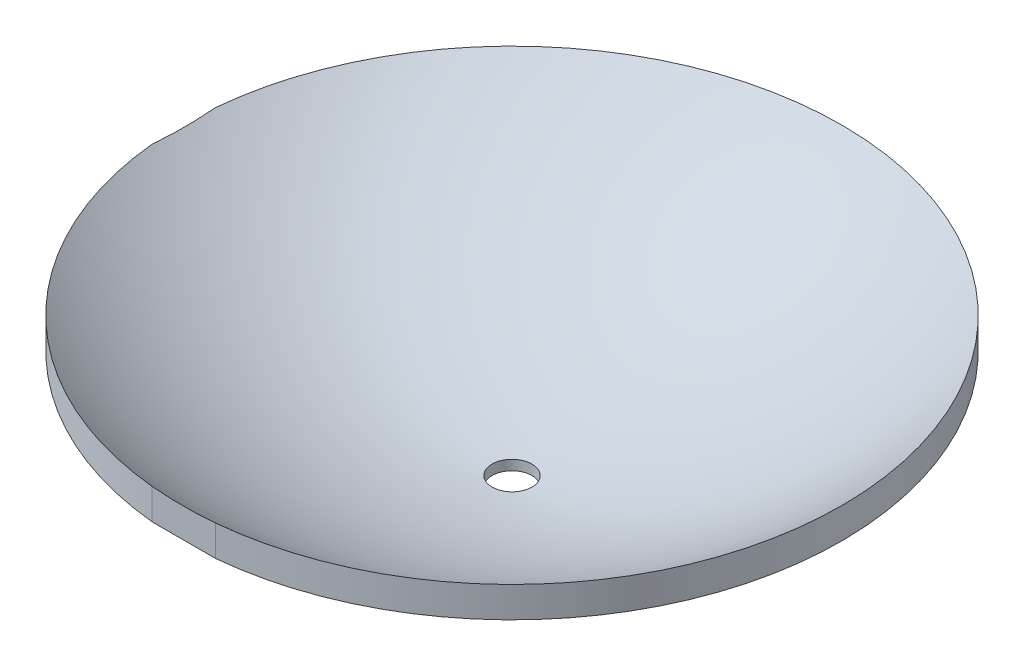
from build123d import *

# Parameters (mm, degrees)
ESQUISSE3_W             = 175.093294054
ESQUISSE3_H             = 36.928767473
ENL_V_MAT_EXTRU_1_DEPTH = 34
ESQUISSE4_W             = 47.307704517
ESQUISSE4_H             = 279.54552669
ENL_V_MAT_EXTRU_2_DEPTH = 41


with BuildPart() as part:
    # Esquisse2 → Révolution1 (revolve)
    with BuildSketch(Plane.XY, mode=Mode.PRIVATE) as r_volution1_sk:
        with BuildLine():
            Line((-15.75, -97), (-13, -97))
            Line((-13, -97), (-13, -90.522038989))
            ThreePointArc((-13, -90.522038989), (-121.553818419, -62.117371137), (-215, 0))
            Line((-215, 0), (-215, -20))
            Line((-215, -20), (-212.5, -20))
            Line((-212.5, -20), (-212.1, -6.361726822))
            ThreePointArc((-212.1, -6.361726822), (-120.864110452, -65.407104105), (-15.75, -93))
            Line((-15.75, -93), (-15.75, -97))
        make_face()
    revolve(r_volution1_sk.sketch.rotate(Axis((0, 0, 0), (0, -1, 0)), 270), axis=Axis((0, 0, 0), (0, -1, 0)))  # turned: the seam where the file's is

    # Esquisse3 → Enlèv. mat.-Extru.1 (cut)
    with BuildSketch(Plane(origin=(0, 0, 0), x_dir=(1, 0, 0), z_dir=(0, 1, 0))):
        with Locations((17.827680849, -232.464383736)):
            Rectangle(ESQUISSE3_W, ESQUISSE3_H)
    extrude(amount=-ENL_V_MAT_EXTRU_1_DEPTH, mode=Mode.SUBTRACT)

    # Esquisse4 → Enlèv. mat.-Extru.2 (cut)
    with BuildSketch(Plane(origin=(0, 0, 0), x_dir=(1, 0, 0), z_dir=(0, 1, 0))):
        with Locations((-237.653852258, -18.411683516)):
            Rectangle(ESQUISSE4_W, ESQUISSE4_H)
    extrude(amount=-ENL_V_MAT_EXTRU_2_DEPTH, mode=Mode.SUBTRACT)


solid = part.part
